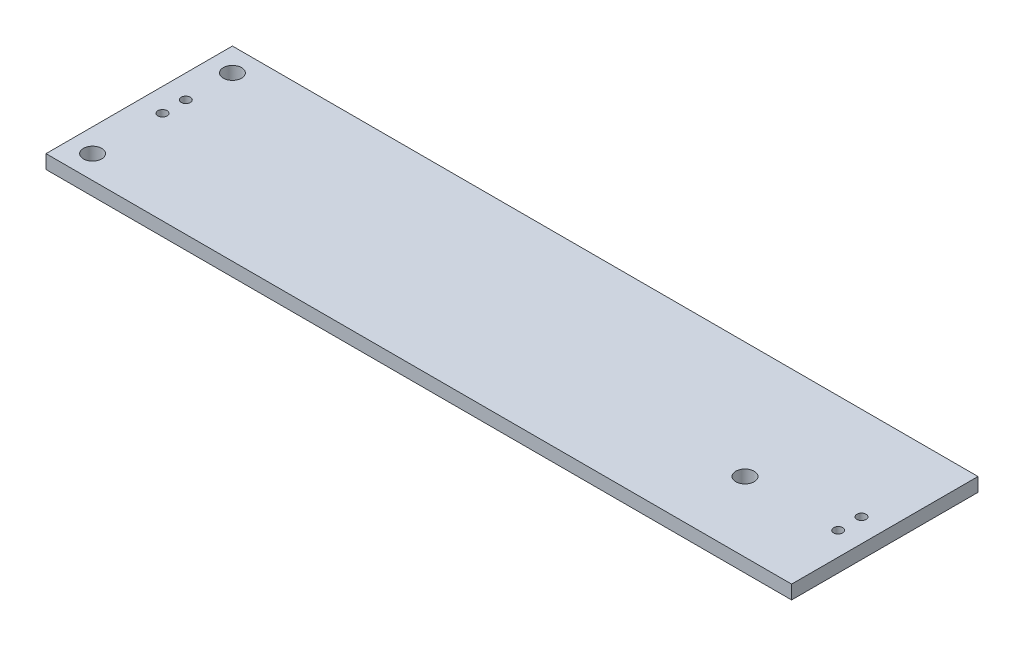
from build123d import *

# Parameters (mm, degrees)
SKETCH1_W           = 81.28
SKETCH1_H           = 20.32
SKETCH1_R           = 1
BOSS_EXTRUDE1_DEPTH = 1.5
SKETCH1_3_R         = 0.5
CUT_EXTRUDE1_DEPTH  = 0.762


with BuildPart() as part:
    # Sketch1 → Boss-Extrude1 (new body)
    with BuildSketch(Plane(origin=(0, 0, 0), x_dir=(1, 0, 0), z_dir=(0, 1, 0))):
        with Locations((40.64, 10.16)):
            Rectangle(SKETCH1_W, SKETCH1_H)
        with Locations(Location((2.54, 2.54, 0), (0, 0, 270))):  # turned: the seam where the file's is
            Circle(SKETCH1_R, mode=Mode.SUBTRACT)
        with Locations(Location((68.58, 7.62, 0), (0, 0, 270))):  # turned: the seam where the file's is
            Circle(SKETCH1_R, mode=Mode.SUBTRACT)
        with Locations(Location((2.54, 17.78, 0), (0, 0, 270))):  # turned: the seam where the file's is
            Circle(SKETCH1_R, mode=Mode.SUBTRACT)
    extrude(amount=-BOSS_EXTRUDE1_DEPTH)

    # Sketch1_3 → Cut-Extrude1 (cut)
    with BuildSketch(Plane(origin=(0, 0, 0), x_dir=(1, 0, 0), z_dir=(0, 1, 0))):
        with Locations(Location((2.54, 12.7, 0), (0, 0, 270))):  # turned: the seam where the file's is
            Circle(SKETCH1_3_R)
        with Locations(Location((2.54, 10.16, 0), (0, 0, 270))):  # turned: the seam where the file's is
            Circle(SKETCH1_3_R)
        with Locations(Location((78.74, 7.62, 0), (0, 0, 270))):  # turned: the seam where the file's is
            Circle(SKETCH1_3_R)
        with Locations(Location((78.74, 10.16, 0), (0, 0, 270))):  # turned: the seam where the file's is
            Circle(SKETCH1_3_R)
    extrude(amount=-CUT_EXTRUDE1_DEPTH, mode=Mode.SUBTRACT)


solid = part.part
